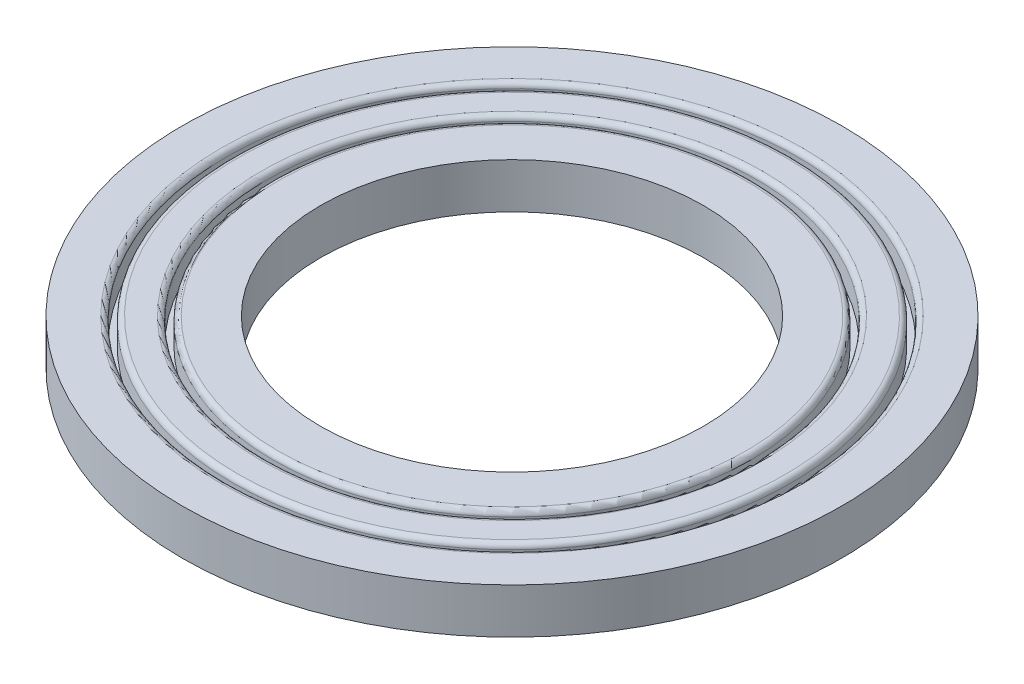
from build123d import *

# Parameters (mm, degrees)
SKETCH_1_R          = 25.5
EXTRUDE_1_DEPTH     = 3.5
SKETCH_2_R          = 19
SKETCH_2_R_2        = 18.5
CUT_EXTRUDE_1_DEPTH = 2
SKETCH_3_R          = 22.1
SKETCH_3_R_2        = 21.6
CUT_EXTRUDE_2_DEPTH = 2
FILLET_1_R          = 0.4
SKETCH_4_R          = 14.809002025
CUT_EXTRUDE_3_DEPTH = 10


with BuildPart() as part:
    # 草图1 → 凸台-拉伸1 (new body)
    with BuildSketch(Plane(origin=(0, 0, 0), x_dir=(1, 0, 0), z_dir=(0, 1, 0))):
        Circle(SKETCH_1_R)
    extrude(amount=EXTRUDE_1_DEPTH)

    # 草图2 → 切除-拉伸1 (cut)
    with BuildSketch(Plane(origin=(0, 3.5, 0), x_dir=(1, 0, 0), z_dir=(0, 1, 0))):
        Circle(SKETCH_2_R)
        Circle(SKETCH_2_R_2, mode=Mode.SUBTRACT)
    extrude(amount=-CUT_EXTRUDE_1_DEPTH, mode=Mode.SUBTRACT)

    # 草图3 → 切除-拉伸2 (cut)
    with BuildSketch(Plane(origin=(0, 3.5, 0), x_dir=(1, 0, 0), z_dir=(0, 1, 0))):
        Circle(SKETCH_3_R)
        Circle(SKETCH_3_R_2, mode=Mode.SUBTRACT)
    extrude(amount=-CUT_EXTRUDE_2_DEPTH, mode=Mode.SUBTRACT)

    # 圆角1
    fillet_1_edges = [part.edges().sort_by_distance(p)[0] for p in [
        (-22.1, 3.5, 0),
        (-21.6, 3.5, 0),
        (-19, 3.5, 0),
        (-18.5, 3.5, 0),
    ]]
    fillet(fillet_1_edges, radius=FILLET_1_R)

    # 草图4 → 切除-拉伸3 (cut)
    with BuildSketch(Plane.XZ):
        Circle(SKETCH_4_R)
    extrude(amount=-CUT_EXTRUDE_3_DEPTH, mode=Mode.SUBTRACT)


solid = part.part
